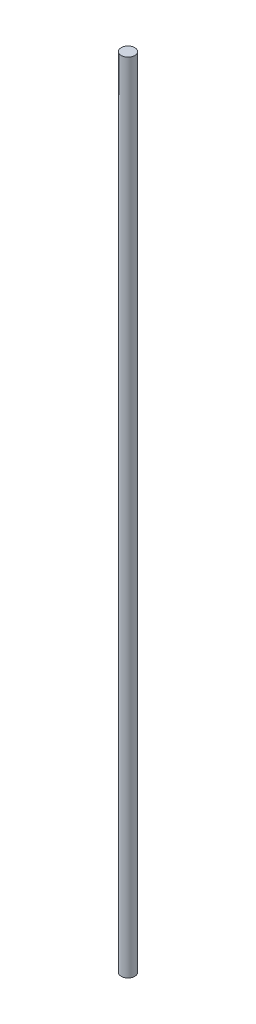
from build123d import *

# Parameters (mm, degrees)
SKETCH1_R           = 0.855
BOSS_EXTRUDE1_DEPTH = 50


with BuildPart() as part:
    # Sketch1 → Boss-Extrude1 (new body, symmetric)
    with BuildSketch(Plane(origin=(0, 0, 0), x_dir=(1, 0, 0), z_dir=(0, 1, 0))):
        Circle(SKETCH1_R)
    extrude(amount=BOSS_EXTRUDE1_DEPTH, both=True)


solid = part.part
